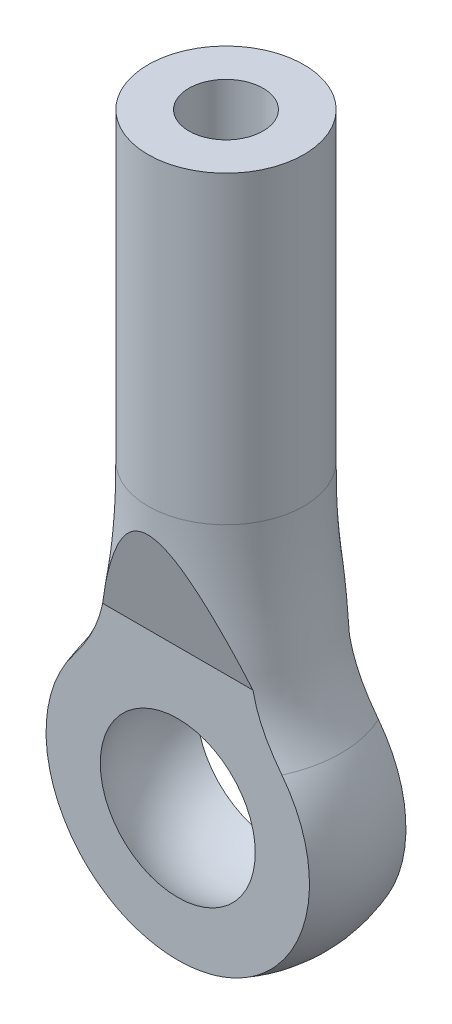
from build123d import *

# Parameters (mm, degrees)
CUT_EXTRUDE1_DEPTH      = 10
CUT_EXTRUDE1_DEPTH_BACK = 10
SKETCH4_R               = 1
CUT_EXTRUDE2_DEPTH      = 10


with BuildPart() as part:
    # Sketch1 → Revolve1 (revolve)
    with BuildSketch(Plane.XY):
        with BuildLine():
            Line((0, 15.65), (-2.1, 15.65))
            Line((-2.1, 15.65), (-2.1, 7.443626247))
            add(Edge.make_bspline(
                [(-2.1, 7.443626247), (-2.1, 6.038956562), (-2.216049734, 5.07485484), (-2.405185663, 3.742666549), (-2.507040855, 3.007798612), (-3.093957369, 2.17159568)],
                knots=[0, 0, 0, 0, 0.498932296, 0.598932296, 1, 1, 1, 1], degree=3))
            ThreePointArc((-3.093957369, 2.17159568), (-3.353880713, -1.743526359), (0, -3.78))
            Line((0, -3.78), (0, 15.65))
        make_face()
    revolve(axis=Axis((0, 15.65, 0), (0, -1, 0)))

    # Sketch2 → Cut-Extrude1 (cut, two sides: drawn at the far end of the back side and taken through both)
    with BuildSketch(Plane(origin=(0, 0, 0), x_dir=(0, 0, -1), z_dir=(1, 0, 0)).offset(-CUT_EXTRUDE1_DEPTH_BACK)):
        Polygon((-1.3, 3.7648943), (-1.3, -3.963127235), (-6.28675197, -3.963127235), (-6.28675197, 4.366468261), (-6.28675197, 9.58144453), (-2.858539937, 9.58144453), align=None)
        Polygon((1.3, 3.7648943), (2.858539937, 9.58144453), (6.28675197, 9.58144453), (6.28675197, 4.366468261), (6.28675197, -3.963127235), (1.3, -3.963127235), align=None)
    extrude(amount=CUT_EXTRUDE1_DEPTH + CUT_EXTRUDE1_DEPTH_BACK, mode=Mode.SUBTRACT)

    # Sketch3 → Cut-Revolve1 (revolve, cut)
    with BuildSketch(Plane.XY):
        with BuildLine():
            Line((0, -2.46), (0, 2.46))
            ThreePointArc((0, 2.46), (-2.46, 0), (0, -2.46))
        make_face()
    revolve(axis=Axis((0, -2.46, 0), (0, 1, 0)), mode=Mode.SUBTRACT)

    # Sketch4 → Cut-Extrude2 (cut)
    with BuildSketch(Plane(origin=(0, 15.65, 0), x_dir=(1, 0, 0), z_dir=(0, 1, 0))):
        Circle(SKETCH4_R)
    extrude(amount=-CUT_EXTRUDE2_DEPTH, mode=Mode.SUBTRACT)


solid = part.part
